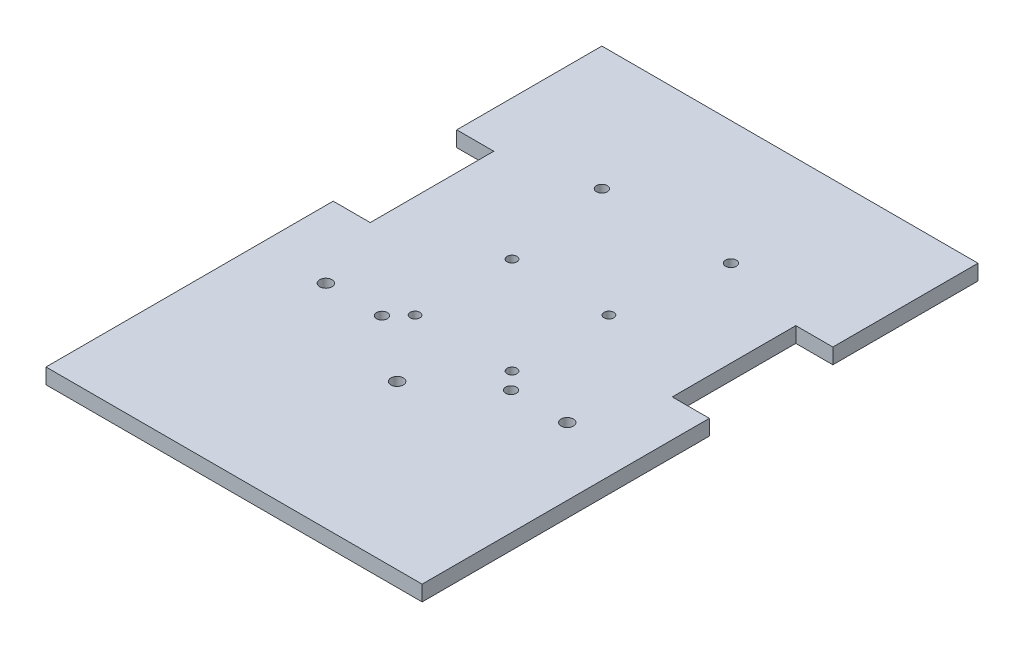
from build123d import *

# Parameters (mm, degrees)
SKETCH2_W           = 154.686
SKETCH2_H           = 228.6
BOSS_EXTRUDE1_DEPTH = 6.35
SKETCH1_R           = 2.2225
CUT_EXTRUDE1_DEPTH  = 6.35
SKETCH3_W           = 15.24
SKETCH3_H           = 50.8
CUT_EXTRUDE2_DEPTH  = 6.35
SKETCH8_R           = 2.54
CUT_EXTRUDE3_DEPTH  = 17.78
SKETCH10_R          = 2
CUT_EXTRUDE4_DEPTH  = 7.35


with BuildPart() as part:
    # Sketch2 → Boss-Extrude1 (new body)
    with BuildSketch(Plane(origin=(0, 0, 0), x_dir=(1, 0, 0), z_dir=(0, 1, 0))):
        with Locations((26.543, 26.944051327)):
            Rectangle(SKETCH2_W, SKETCH2_H)
    extrude(amount=BOSS_EXTRUDE1_DEPTH)

    # Sketch1 → Cut-Extrude1 (cut)
    with BuildSketch(Plane(origin=(0, 0, 0), x_dir=(1, 0, 0), z_dir=(0, 1, 0))):
        with Locations((0, 90.444051327)):
            Circle(SKETCH1_R)
        with Locations((53.086, 90.444051327)):
            Circle(SKETCH1_R)
        Circle(SKETCH1_R)
        with Locations((53.086, 0)):
            Circle(SKETCH1_R)
    extrude(amount=CUT_EXTRUDE1_DEPTH, mode=Mode.SUBTRACT)

    # Sketch3 → Cut-Extrude2 (cut)
    with BuildSketch(Plane(origin=(0, 6.35, 0), x_dir=(1, 0, 0), z_dir=(0, 1, 0))):
        with Locations((96.266, 56.154051327)):
            Rectangle(SKETCH3_W, SKETCH3_H)
        with Locations((-43.18, 56.154051327)):
            Rectangle(SKETCH3_W, SKETCH3_H)
    extrude(amount=-CUT_EXTRUDE2_DEPTH, mode=Mode.SUBTRACT)

    # Sketch8 → Cut-Extrude3 (cut)
    with BuildSketch(Plane(origin=(0, 6.35, 0), x_dir=(1, 0, 0), z_dir=(0, 1, 0))):
        with Locations((26.550112, -20.29968)):
            Circle(SKETCH8_R)
        with Locations((-23.077082804, 0.02032)):
            Circle(SKETCH8_R)
        with Locations((76.177306804, 0.02032)):
            Circle(SKETCH8_R)
    extrude(amount=-CUT_EXTRUDE3_DEPTH, mode=Mode.SUBTRACT)

    # Sketch10 → Cut-Extrude4 (cut, through all)
    with BuildSketch(Plane(origin=(0, 6.35, 0), x_dir=(1, 0, 0), z_dir=(0, 1, 0))):
        with Locations((6.604, 7.005051327)):
            Circle(SKETCH10_R)
        with Locations((46.482, 7.005051327)):
            Circle(SKETCH10_R)
        with Locations((46.482, 46.883051327)):
            Circle(SKETCH10_R)
        with Locations((6.604, 46.883051327)):
            Circle(SKETCH10_R)
    extrude(amount=-CUT_EXTRUDE4_DEPTH, mode=Mode.SUBTRACT)


solid = part.part
